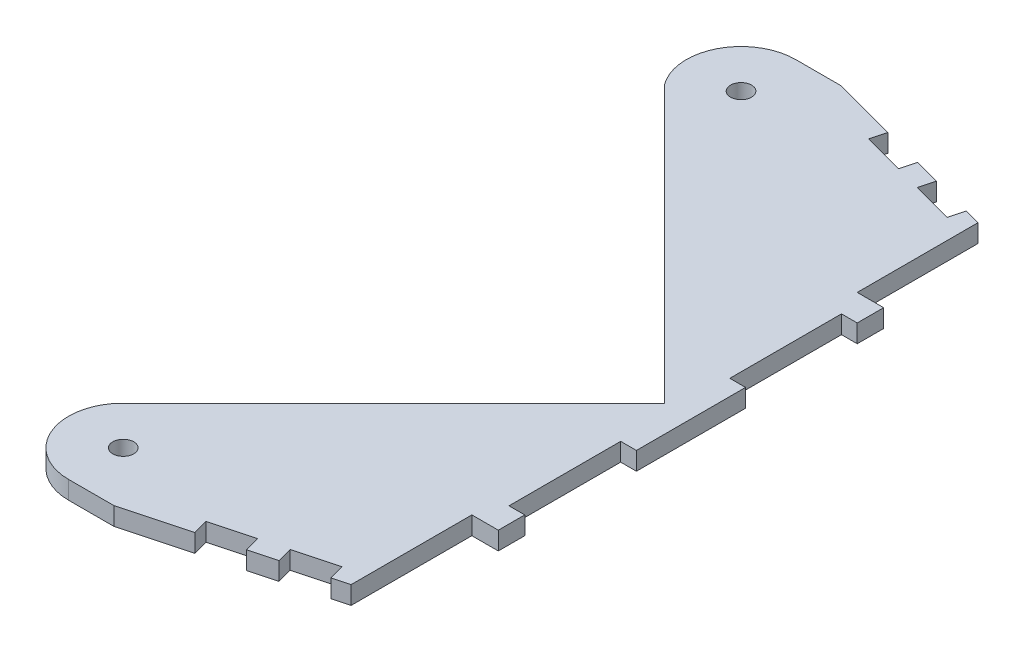
from build123d import *

# Parameters (mm, degrees)
SKETCH1_R           = 3.175
BOSS_EXTRUDE1_DEPTH = 5.461
SKETCH3_W           = 4.7625
SKETCH3_H           = 33.783
CUT_EXTRUDE2_DEPTH  = 10


with BuildPart() as part:
    # Sketch1 → Boss-Extrude1 (new body)
    with BuildSketch(Plane(origin=(0, 0, 0), x_dir=(1, 0, 0), z_dir=(0, 1, 0))):
        with BuildLine():
            Line((0, 0), (-83.629476528, 83.629476528))
            ThreePointArc((-83.629476528, 83.629476528), (-85.081850373, 100.91197572), (-70.310188895, 110))
            Line((-70.310188895, 110), (-56.601944845, 110))
            Line((-56.601944845, 110), (0, 94.833554589))
            Line((0, 94.833554589), (0, 58.293))
            Line((0, 58.293), (8, 58.293))
            Line((8, 58.293), (8, -58.293))
            Line((8, -58.293), (0, -58.293))
            Line((0, -58.293), (0, -94.833554589))
            Line((0, -94.833554589), (-56.601944845, -110))
            Line((-56.601944845, -110), (-70.310188895, -110))
            ThreePointArc((-70.310188895, -110), (-85.081850373, -100.91197572), (-83.629476528, -83.629476528))
            Line((-83.629476528, -83.629476528), (0, 0))
        make_face()
        with Locations((-70.310188895, 93.451069294)):
            Circle(SKETCH1_R, mode=Mode.SUBTRACT)
        with Locations((-70.310188895, -93.451069294)):
            Circle(SKETCH1_R, mode=Mode.SUBTRACT)
    extrude(amount=BOSS_EXTRUDE1_DEPTH)

    # Sketch3 → Cut-Extrude2 (cut)
    with BuildSketch(Plane(origin=(0, 0, 0), x_dir=(1, 0, 0), z_dir=(0, 1, 0))):
        Polygon((-37.283428319, 104.823619098), (-24.920232031, 101.510910637), (-26.152857733, 96.910688889), (-38.516054022, 100.22339735), align=None)
        Polygon((-17.19282542, 99.440358276), (-4.829629131, 96.127649814), (-6.062254834, 91.527428067), (-18.425451123, 94.840136528), align=None)
        Polygon((-18.425451123, -94.840136528), (-6.062254834, -91.527428067), (-4.829629131, -96.127649814), (-17.19282542, -99.440358276), align=None)
        Polygon((-38.516054022, -100.22339735), (-26.152857733, -96.910688889), (-24.920232031, -101.510910637), (-37.283428319, -104.823619098), align=None)
        with Locations((5.61875, 33.4015)):
            Rectangle(SKETCH3_W, SKETCH3_H)
        with Locations((5.61875, -33.4015)):
            Rectangle(SKETCH3_W, SKETCH3_H)
    extrude(amount=CUT_EXTRUDE2_DEPTH, mode=Mode.SUBTRACT)


solid = part.part
